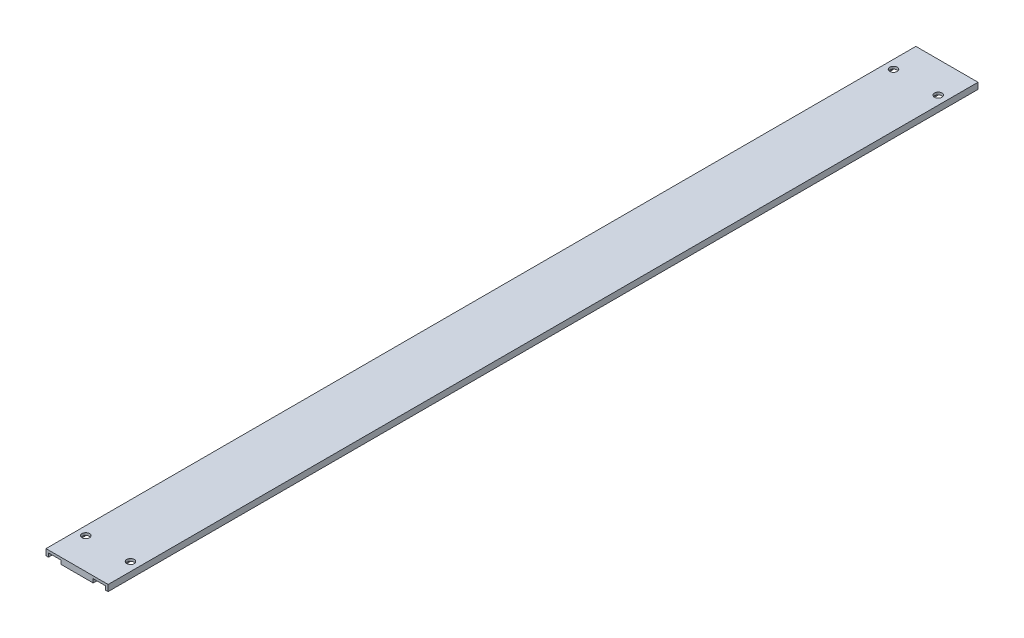
from build123d import *

# Parameters (mm, degrees)
SKETCH1_W           = 50
SKETCH1_H           = 700
BOSS_EXTRUDE1_DEPTH = 5
SKETCH6_R           = 3
CUT_EXTRUDE3_DEPTH  = 6
SKETCH11_W          = 10
SKETCH11_H          = 700
CUT_EXTRUDE4_DEPTH  = 3


with BuildPart() as part:
    # Sketch1 → Boss-Extrude1 (new body)
    with BuildSketch(Plane(origin=(0, 0, 0), x_dir=(1, 0, 0), z_dir=(0, 1, 0))):
        with Locations((25, 350)):
            Rectangle(SKETCH1_W, SKETCH1_H)
    extrude(amount=BOSS_EXTRUDE1_DEPTH)

    # Sketch6 → Cut-Extrude3 (cut, through all)
    with BuildSketch(Plane(origin=(0, 5, 0), x_dir=(1, 0, 0), z_dir=(0, 1, 0))):
        with Locations((43, 25)):
            Circle(SKETCH6_R)
        with Locations((7, 25)):
            Circle(SKETCH6_R)
        with Locations((43, 675)):
            Circle(SKETCH6_R)
        with Locations((7, 675)):
            Circle(SKETCH6_R)
    extrude(amount=-CUT_EXTRUDE3_DEPTH, mode=Mode.SUBTRACT)

    # Sketch11 → Cut-Extrude4 (cut)
    with BuildSketch(Plane.XZ):
        with Locations((7, -350)):
            Rectangle(SKETCH11_W, SKETCH11_H)
        with Locations((43, -350)):
            Rectangle(SKETCH11_W, SKETCH11_H)
    extrude(amount=-CUT_EXTRUDE4_DEPTH, mode=Mode.SUBTRACT)


solid = part.part
